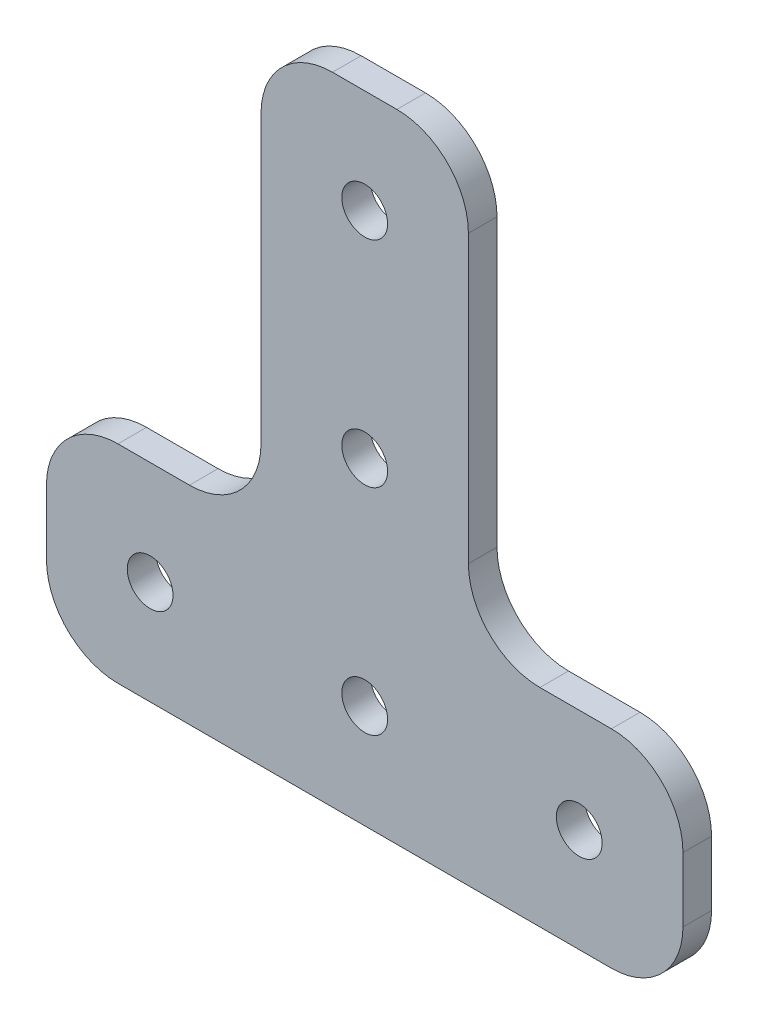
from build123d import *

# Parameters (mm, degrees)
SKETCH1_R           = 1.6
BOSS_EXTRUDE1_DEPTH = 2
FILLET1_R           = 5


with BuildPart() as part:
    # Sketch1 → Boss-Extrude1 (new body)
    with BuildSketch(Plane.XY):
        Polygon((-22.25, 0), (22.25, 0), (22.25, 14.5), (7.25, 14.5), (7.25, 44.5), (-7.25, 44.5), (-7.25, 14.5), (-22.25, 14.5), align=None)
        with Locations((0, 7.25)):
            Circle(SKETCH1_R, mode=Mode.SUBTRACT)
        with Locations((15, 7.25)):
            Circle(SKETCH1_R, mode=Mode.SUBTRACT)
        with Locations((0, 22.25)):
            Circle(SKETCH1_R, mode=Mode.SUBTRACT)
        with Locations((0, 37.25)):
            Circle(SKETCH1_R, mode=Mode.SUBTRACT)
        with Locations((-15, 7.25)):
            Circle(SKETCH1_R, mode=Mode.SUBTRACT)
    extrude(amount=BOSS_EXTRUDE1_DEPTH)

    # Fillet1
    fillet1_edges = [part.edges().sort_by_distance(p)[0] for p in [
        (22.25, 14.5, 1),
        (22.25, 0, 1),
        (-22.25, 0, 1),
        (-22.25, 14.5, 1),
        (-7.25, 14.5, 1),
        (-7.25, 44.5, 1),
        (7.25, 44.5, 1),
        (7.25, 14.5, 1),
    ]]
    fillet(fillet1_edges, radius=FILLET1_R)


solid = part.part
